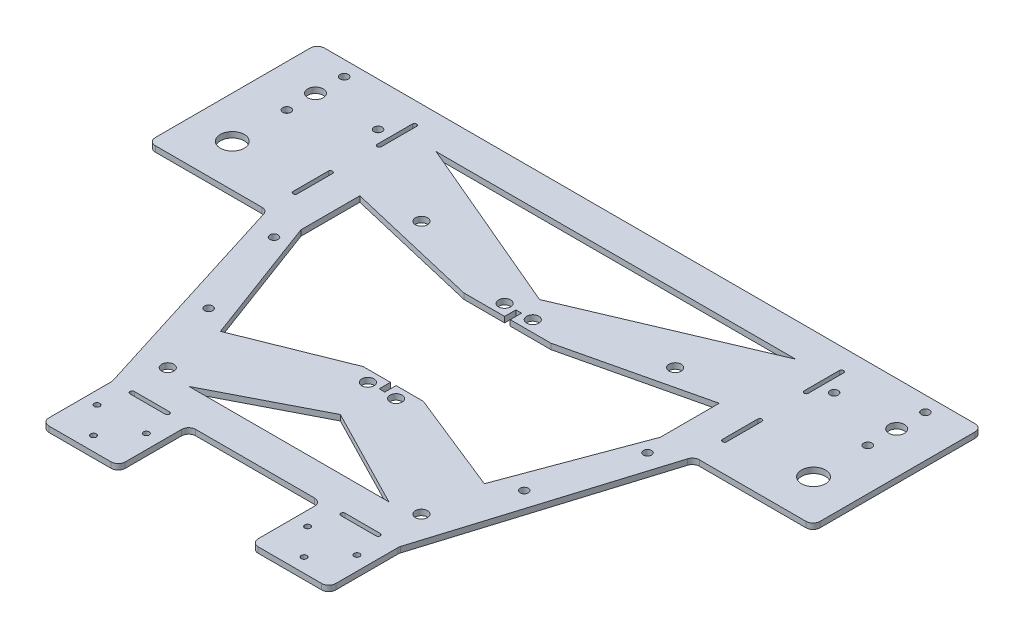
from build123d import *

# Parameters (mm, degrees)
SKETCH26_R          = 1
SKETCH26_R_2        = 2.15
SKETCH26_R_3        = 1.45
SKETCH26_R_4        = 4.25
SKETCH26_R_5        = 2.75
BOSS_EXTRUDE4_DEPTH = 2


with BuildPart() as part:
    # Sketch26 → Boss-Extrude4 (new body)
    with BuildSketch(Plane(origin=(0, 0, 0), x_dir=(1, 0, 0), z_dir=(0, 1, 0))):
        with BuildLine():
            Line((-20.823616498, -51.176455051), (21.352676296, -51.176455051))
            ThreePointArc((21.352676296, -51.176455051), (23.120443249, -51.908688098), (23.852676296, -53.676455051))
            Line((23.852676296, -53.676455051), (23.852676296, -73.676455051))
            ThreePointArc((23.852676296, -73.676455051), (24.584909343, -75.444222004), (26.352676296, -76.176455051))
            Line((26.352676296, -76.176455051), (48.872676296, -76.176455051))
            ThreePointArc((48.872676296, -76.176455051), (50.640443249, -75.444222004), (51.372676296, -73.676455051))
            Line((51.372676296, -73.676455051), (51.372676296, -51.552742091))
            ThreePointArc((51.372676296, -51.552742091), (51.400522432, -51.180646307), (51.483440514, -50.816839667))
            Line((51.483440514, -50.816839667), (75.469917209, 27.059447373))
            ThreePointArc((75.469917209, 27.059447373), (76.374187682, 28.334733163), (77.859152991, 28.823544949))
            Line((77.859152991, 28.823544949), (115.689249226, 28.823544949))
            ThreePointArc((115.689249226, 28.823544949), (117.457016179, 29.555777996), (118.189249226, 31.323544949))
            Line((118.189249226, 31.323544949), (118.189249226, 86.323544949))
            ThreePointArc((118.189249226, 86.323544949), (117.457016179, 88.091311902), (115.689249226, 88.823544949))
            Line((115.689249226, 88.823544949), (76.013272408, 88.823544949))
            Line((76.013272408, 88.823544949), (-75.48421261, 88.823544949))
            Line((-75.48421261, 88.823544949), (-76.032763958, 88.823544949))
            Line((-76.032763958, 88.823544949), (-115.160189428, 88.823544949))
            ThreePointArc((-115.160189428, 88.823544949), (-116.927956381, 88.091311902), (-117.660189428, 86.323544949))
            Line((-117.660189428, 86.323544949), (-117.660189428, 31.323544949))
            ThreePointArc((-117.660189428, 31.323544949), (-116.927956381, 29.555777996), (-115.160189428, 28.823544949))
            Line((-115.160189428, 28.823544949), (-77.320558078, 28.823544949))
            ThreePointArc((-77.320558078, 28.823544949), (-75.840570727, 28.338399148), (-74.934991096, 27.071254903))
            Line((-74.934991096, 27.071254903), (-50.523941264, -50.812146542))
            ThreePointArc((-50.523941264, -50.812146542), (-50.438282088, -51.18164852), (-50.409508246, -51.559856495))
            Line((-50.409508246, -51.559856495), (-50.409508246, -73.676455051))
            ThreePointArc((-50.409508246, -73.676455051), (-49.677275199, -75.444222004), (-47.909508246, -76.176455051))
            Line((-47.909508246, -76.176455051), (-25.823616498, -76.176455051))
            ThreePointArc((-25.823616498, -76.176455051), (-24.055849545, -75.444222004), (-23.323616498, -73.676455051))
            Line((-23.323616498, -73.676455051), (-23.323616498, -53.676455051))
            ThreePointArc((-23.323616498, -53.676455051), (-22.591383451, -51.908688098), (-20.823616498, -51.176455051))
        make_face()
        with Locations((-37.083616498, -71.176455051)):
            Circle(SKETCH26_R, mode=Mode.SUBTRACT)
        with Locations((-45.843616498, -61.176455051)):
            Circle(SKETCH26_R, mode=Mode.SUBTRACT)
        with Locations((-28.323616498, -61.176455051)):
            Circle(SKETCH26_R, mode=Mode.SUBTRACT)
        with BuildLine():
            Line((-43.378108588, -50.422722318), (-30.878108588, -50.422722318))
            ThreePointArc((-30.878108588, -50.422722318), (-30.128108588, -51.172722318), (-30.878108588, -51.922722318))
            Line((-30.878108588, -51.922722318), (-43.378108588, -51.922722318))
            ThreePointArc((-43.378108588, -51.922722318), (-44.128108588, -51.172722318), (-43.378108588, -50.422722318))
        make_face(mode=Mode.SUBTRACT)
        with Locations((-44.735470101, -37.176455051)):
            Circle(SKETCH26_R_2, mode=Mode.SUBTRACT)
        with Locations((-55.732763009, -11.697986619)):
            Circle(SKETCH26_R_3, mode=Mode.SUBTRACT)
        with Locations((-4.735470101, -6.176455051)):
            Circle(SKETCH26_R_2, mode=Mode.SUBTRACT)
        with Locations((28.852676296, -61.176455051)):
            Circle(SKETCH26_R, mode=Mode.SUBTRACT)
        with Locations((37.612676296, -71.176455051)):
            Circle(SKETCH26_R, mode=Mode.SUBTRACT)
        with Locations((46.372676296, -61.176455051)):
            Circle(SKETCH26_R, mode=Mode.SUBTRACT)
        with BuildLine():
            ThreePointArc((31.407168386, -51.922722318), (30.657168386, -51.172722318), (31.407168386, -50.422722318))
            Line((31.407168386, -50.422722318), (43.907168386, -50.422722318))
            ThreePointArc((43.907168386, -50.422722318), (44.657168386, -51.172722318), (43.907168386, -51.922722318))
            Line((43.907168386, -51.922722318), (31.407168386, -51.922722318))
        make_face(mode=Mode.SUBTRACT)
        with Locations((45.264529899, -37.176455051)):
            Circle(SKETCH26_R_2, mode=Mode.SUBTRACT)
        Polygon((35.712257561, -39.176455051), (-35.183197763, -39.176455051), (0.264529899, -20.951240159), align=None, mode=Mode.SUBTRACT)
        with Locations((5.264529899, -6.176455051)):
            Circle(SKETCH26_R_2, mode=Mode.SUBTRACT)
        with Locations((56.261822807, -11.697986619)):
            Circle(SKETCH26_R_3, mode=Mode.SUBTRACT)
        with Locations((-65.98606306, 21.76646972)):
            Circle(SKETCH26_R_3, mode=Mode.SUBTRACT)
        with Locations((-102.838209752, 43.823544949)):
            Circle(SKETCH26_R_4, mode=Mode.SUBTRACT)
        with BuildLine():
            ThreePointArc((-75.160005035, 39.191107079), (-75.910005035, 38.441107079), (-76.660005035, 39.191107079))
            Line((-76.660005035, 39.191107079), (-76.660005035, 51.691107079))
            ThreePointArc((-76.660005035, 51.691107079), (-75.910005035, 52.441107079), (-75.160005035, 51.691107079))
            Line((-75.160005035, 51.691107079), (-75.160005035, 39.191107079))
        make_face(mode=Mode.SUBTRACT)
        with Locations((-4.735470101, 42.323544949)):
            Circle(SKETCH26_R_2, mode=Mode.SUBTRACT)
        with Locations((-102.78421261, 63.123687889)):
            Circle(SKETCH26_R_3, mode=Mode.SUBTRACT)
        with Locations((-102.838212164, 73.323544949)):
            Circle(SKETCH26_R_5, mode=Mode.SUBTRACT)
        with Locations((-102.838214468, 83.523544949)):
            Circle(SKETCH26_R_3, mode=Mode.SUBTRACT)
        with Locations((-80.638212164, 73.323544949)):
            Circle(SKETCH26_R_3, mode=Mode.SUBTRACT)
        with BuildLine():
            ThreePointArc((-76.23421261, 81.095149015), (-75.48421261, 81.845149015), (-74.73421261, 81.095149015))
            Line((-74.73421261, 81.095149015), (-74.73421261, 68.595149015))
            ThreePointArc((-74.73421261, 68.595149015), (-75.48421261, 67.845149015), (-76.23421261, 68.595149015))
            Line((-76.23421261, 68.595149015), (-76.23421261, 81.095149015))
        make_face(mode=Mode.SUBTRACT)
        with Locations((-44.735470101, 52.823544949)):
            Circle(SKETCH26_R_2, mode=Mode.SUBTRACT)
        Polygon((-10.402901984, -2.176455051), (-46.543802783, -16.676455051), (-63.48421261, 28.823544949), (-63.48421261, 49.70968094), (-15.178445609, 38.323544949), (-0.735470101, 38.323544949), (-0.735470101, 42.323544949), (1.264529899, 42.323544949), (1.264529899, 38.323544949), (15.707505407, 38.323544949), (64.013272408, 49.70968094), (64.013272408, 28.823544949), (47.072862581, -16.676455051), (10.931961782, -2.176455051), (1.264529899, -2.176455051), (1.264529899, -6.176455051), (-0.735470101, -6.176455051), (-0.735470101, -2.176455051), align=None, mode=Mode.SUBTRACT)
        with Locations((5.264529899, 42.323544949)):
            Circle(SKETCH26_R_2, mode=Mode.SUBTRACT)
        with Locations((66.515122858, 21.76646972)):
            Circle(SKETCH26_R_3, mode=Mode.SUBTRACT)
        with BuildLine():
            Line((77.189064833, 51.691107079), (77.189064833, 39.191107079))
            ThreePointArc((77.189064833, 39.191107079), (76.439064833, 38.441107079), (75.689064833, 39.191107079))
            Line((75.689064833, 39.191107079), (75.689064833, 51.691107079))
            ThreePointArc((75.689064833, 51.691107079), (76.439064833, 52.441107079), (77.189064833, 51.691107079))
        make_face(mode=Mode.SUBTRACT)
        with Locations((103.367269549, 43.823544949)):
            Circle(SKETCH26_R_4, mode=Mode.SUBTRACT)
        Polygon((0.264529899, 49.70968094), (-63.538214468, 76.823544949), (64.067274266, 76.823544949), align=None, mode=Mode.SUBTRACT)
        with Locations((45.264529899, 52.823544949)):
            Circle(SKETCH26_R_2, mode=Mode.SUBTRACT)
        with Locations((103.313272408, 63.123687889)):
            Circle(SKETCH26_R_3, mode=Mode.SUBTRACT)
        with Locations((81.167271962, 73.323544949)):
            Circle(SKETCH26_R_3, mode=Mode.SUBTRACT)
        with BuildLine():
            Line((75.263272408, 68.595149015), (75.263272408, 81.095149015))
            ThreePointArc((75.263272408, 81.095149015), (76.013272408, 81.845149015), (76.763272408, 81.095149015))
            Line((76.763272408, 81.095149015), (76.763272408, 68.595149015))
            ThreePointArc((76.763272408, 68.595149015), (76.013272408, 67.845149015), (75.263272408, 68.595149015))
        make_face(mode=Mode.SUBTRACT)
        with Locations((103.367271962, 73.323544949)):
            Circle(SKETCH26_R_5, mode=Mode.SUBTRACT)
        with Locations((103.367274266, 83.523544949)):
            Circle(SKETCH26_R_3, mode=Mode.SUBTRACT)
    extrude(amount=BOSS_EXTRUDE4_DEPTH)


solid = part.part
